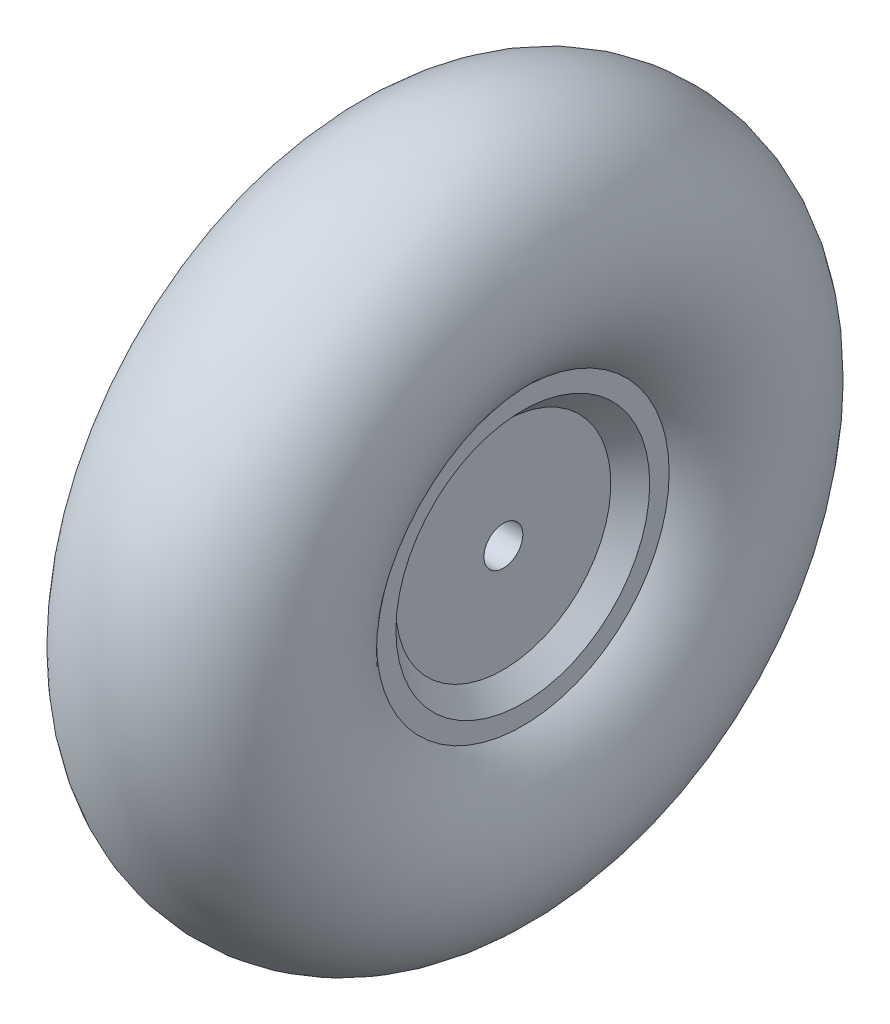
from build123d import *


with BuildPart() as part:
    # Sketch1 → Revolve1 (revolve)
    with BuildSketch(Plane.XY):
        with BuildLine():
            ThreePointArc((-12.7, 23.900968343), (0, 57.15), (12.7, 23.900968343))
            Line((12.7, 23.900968343), (12.7, 20.725968343))
            Line((12.7, 20.725968343), (9.525, 17.550968343))
            Line((9.525, 17.550968343), (9.525, 3.175))
            Line((9.525, 3.175), (-9.525, 3.175))
            Line((-9.525, 3.175), (-9.525, 17.550968343))
            Line((-9.525, 17.550968343), (-12.7, 20.725968343))
            Line((-12.7, 20.725968343), (-12.7, 23.900968343))
        make_face()
    revolve(axis=Axis((-53.506986498, 0, 0), (1, 0, 0)))


solid = part.part
